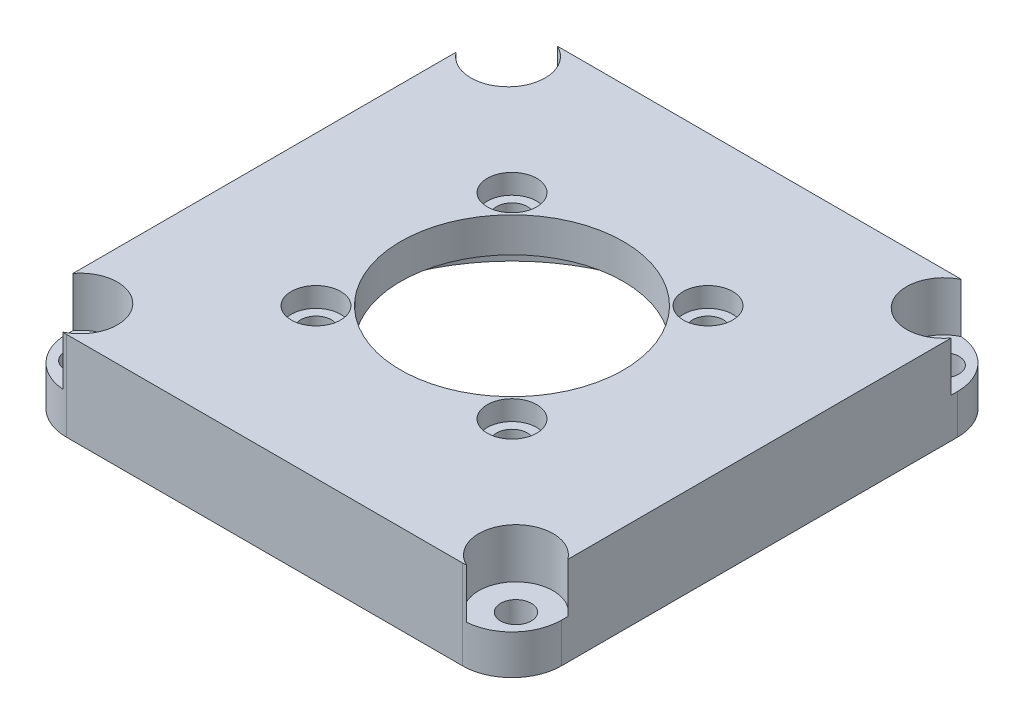
from build123d import *

# Parameters (mm, degrees)
SKETCH1_W               = 50
SKETCH1_H               = 50
BOSS_EXTRUDE1_DEPTH     = 12
FILLET1_R               = 5
SKETCH3_R               = 18.25
CUT_EXTRUDE1_DEPTH      = 5.5
SKETCH4_R               = 11.25
CUT_EXTRUDE2_DEPTH      = 10
SKETCH5_W               = 62.97921445
SKETCH5_H               = 70.453436458
CUT_EXTRUDE3_DEPTH      = 3
SKETCH6_R               = 2.5
CUT_EXTRUDE4_DEPTH      = 2
SKETCH7_R               = 1.55
CUT_EXTRUDE5_DEPTH      = 3
SKETCH8_R               = 1.55
CUT_EXTRUDE6_DEPTH      = 12
SKETCH9_R               = 3.75
CUT_EXTRUDE7_DEPTH      = 5
MIRROR2_COPY_1_SKETCH_R = 1.55
MIRROR2_COPY_1_DEPTH    = 12
MIRROR2_COPY_2_SKETCH_R = 3.75
MIRROR2_COPY_2_DEPTH    = 5


with BuildPart() as part:
    # Sketch1 → Boss-Extrude1 (new body)
    with BuildSketch(Plane(origin=(0, 0, 0), x_dir=(1, 0, 0), z_dir=(0, 1, 0))):
        Rectangle(SKETCH1_W, SKETCH1_H)
    extrude(amount=BOSS_EXTRUDE1_DEPTH)

    # Fillet1
    fillet1_edges = [part.edges().sort_by_distance(p)[0] for p in [
        (25, 6, 25),
        (-25, 6, 25),
        (-25, 6, -25),
        (25, 6, -25),
    ]]
    fillet(fillet1_edges, radius=FILLET1_R)

    # Sketch3 → Cut-Extrude1 (cut)
    with BuildSketch(Plane.XZ):
        Circle(SKETCH3_R)
    extrude(amount=-CUT_EXTRUDE1_DEPTH, mode=Mode.SUBTRACT)

    # Sketch4 → Cut-Extrude2 (cut)
    with BuildSketch(Plane.XZ.offset(-5.5)):
        Circle(SKETCH4_R)
    extrude(amount=-CUT_EXTRUDE2_DEPTH, mode=Mode.SUBTRACT)

    # Sketch5 → Cut-Extrude3 (cut)
    with BuildSketch(Plane(origin=(0, 12, 0), x_dir=(1, 0, 0), z_dir=(0, 1, 0))):
        Rectangle(SKETCH5_W, SKETCH5_H)
    extrude(amount=-CUT_EXTRUDE3_DEPTH, mode=Mode.SUBTRACT)

    # Sketch6 → Cut-Extrude4 (cut)
    with BuildSketch(Plane(origin=(0, 9, 0), x_dir=(1, 0, 0), z_dir=(0, 1, 0))):
        with Locations((-9.899494937, 9.899494937)):
            Circle(SKETCH6_R)
        with Locations((9.899494937, 9.899494937)):
            Circle(SKETCH6_R)
        with Locations((-9.899494937, -9.899494937)):
            Circle(SKETCH6_R)
        with Locations((9.899494937, -9.899494937)):
            Circle(SKETCH6_R)
    extrude(amount=-CUT_EXTRUDE4_DEPTH, mode=Mode.SUBTRACT)

    # Sketch7 → Cut-Extrude5 (cut)
    with BuildSketch(Plane(origin=(0, 7, 0), x_dir=(1, 0, 0), z_dir=(0, 1, 0))):
        with Locations((-9.899494937, 9.899494937)):
            Circle(SKETCH7_R)
        with Locations((9.899494937, 9.899494937)):
            Circle(SKETCH7_R)
        with Locations((-9.899494937, -9.899494937)):
            Circle(SKETCH7_R)
        with Locations((9.899494937, -9.899494937)):
            Circle(SKETCH7_R)
    extrude(amount=-CUT_EXTRUDE5_DEPTH, mode=Mode.SUBTRACT)

    # Sketch8 → Cut-Extrude6 (cut)
    with BuildSketch(Plane(origin=(0, 9, 0), x_dir=(1, 0, 0), z_dir=(0, 1, 0))):
        with Locations((-22, 21.6)):
            Circle(SKETCH8_R)
    cut_extrude6 = extrude(amount=-CUT_EXTRUDE6_DEPTH, mode=Mode.SUBTRACT)

    # Sketch9 → Cut-Extrude7 (cut)
    with BuildSketch(Plane(origin=(0, 9, 0), x_dir=(1, 0, 0), z_dir=(0, 1, 0))):
        with Locations((-22, 21.6)):
            Circle(SKETCH9_R)
    cut_extrude7 = extrude(amount=-CUT_EXTRUDE7_DEPTH, mode=Mode.SUBTRACT)

    # Mirror1: Cut-Extrude6, Cut-Extrude7 across plane
    add(cut_extrude6.mirror(Plane(origin=(0, 0, 0), x_dir=(0, 0, 1), z_dir=(1, 0, 0))), mode=Mode.SUBTRACT)
    add(cut_extrude7.mirror(Plane(origin=(0, 0, 0), x_dir=(0, 0, 1), z_dir=(1, 0, 0))), mode=Mode.SUBTRACT)

    # Mirror2: Cut-Extrude6, Cut-Extrude7 across plane
    add(cut_extrude6.mirror(Plane.XY), mode=Mode.SUBTRACT)
    add(cut_extrude7.mirror(Plane.XY), mode=Mode.SUBTRACT)

    # Mirror2 copy 1 sketch → Mirror2 copy 1 (cut)
    with BuildSketch(Plane(origin=(0, 9, 0), x_dir=(-1, 0, 0), z_dir=(0, 1, 0))):
        with Locations((-22, 21.6)):
            Circle(MIRROR2_COPY_1_SKETCH_R)
    extrude(amount=-MIRROR2_COPY_1_DEPTH, mode=Mode.SUBTRACT)

    # Mirror2 copy 2 sketch → Mirror2 copy 2 (cut)
    with BuildSketch(Plane(origin=(0, 9, 0), x_dir=(-1, 0, 0), z_dir=(0, 1, 0))):
        with Locations((-22, 21.6)):
            Circle(MIRROR2_COPY_2_SKETCH_R)
    extrude(amount=-MIRROR2_COPY_2_DEPTH, mode=Mode.SUBTRACT)


solid = part.part
